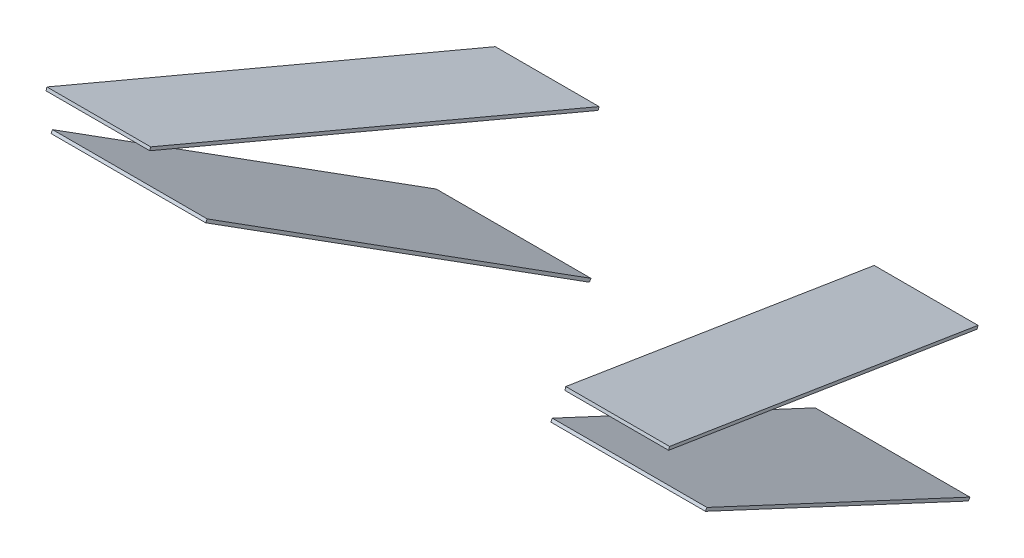
from build123d import *

# Parameters (mm, degrees)
BOSS_EXTRUDE1_DEPTH = 1.5
BOSS_EXTRUDE2_DEPTH = 1.5


with BuildPart() as part:
    # Sketch1 → Boss-Extrude1 (new body)
    with BuildSketch(Plane(origin=(0, 329.699604605, -103.953886026), x_dir=(1, 0, 0), z_dir=(0, 0.953716951, -0.3007058))):
        Polygon((102, 27.217157705), (153, 27.217157705), (118.616238762, 222.217157705), (67.616238762, 222.217157705), align=None)
    extrude(amount=BOSS_EXTRUDE1_DEPTH)


with BuildPart() as body_2:
    # Sketch2 → Boss-Extrude2 (new body)
    with BuildSketch(Plane(origin=(0, 283.022482375, -160.126416143), x_dir=(1, 0, 0), z_dir=(0, -0.870355696, 0.49242356))):
        Polygon((84.810060817, 22.910464575), (160.810060817, 22.910464575), (131.12, -159.691562491), (55.12, -159.691562491), align=None)
    extrude(amount=-BOSS_EXTRUDE2_DEPTH)


with BuildPart() as body_3:
    # Mirror2: mirrored copy
    add(part.part.mirror(Plane(origin=(0, 0, 0), x_dir=(0, 0, 1), z_dir=(1, 0, 0))))


with BuildPart() as body_4:
    # Mirror2 2: mirrored copy
    add(body_2.part.mirror(Plane(origin=(0, 0, 0), x_dir=(0, 0, 1), z_dir=(1, 0, 0))))


solid = Compound([part.part, body_2.part, body_3.part, body_4.part])
